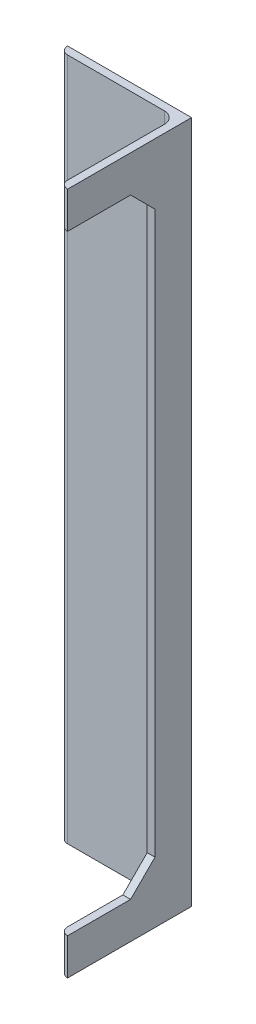
from build123d import *

# Parameters (mm, degrees)
ANGULAR_ALUMINIO_ANGULAR_38MM_1_DEPTH = 280
CROQUIS8_W                            = 35.8
CROQUIS8_H                            = 250
CORTAR_EXTRUIR1_DEPTH                 = 4
CHAFL_N1_SIZE                         = 10
CROQUIS10_R                           = 2
CORTAR_EXTRUIR3_DEPTH                 = 10
CROQUIS12_R                           = 2
CORTAR_EXTRUIR4_DEPTH                 = 10


with BuildPart() as part:
    # Sketch11 → Angular ALUMINIO ANGULAR 38MM(1) (new body)
    with BuildSketch(Plane(origin=(0, 0, 0), x_dir=(-1, 0, 0), z_dir=(0, 1, 0))):
        with BuildLine():
            Line((0, 0), (0, 50.8))
            Line((0, 50.8), (0.00508, 50.8))
            ThreePointArc((0.00508, 50.8), (2.246551928, 49.871551928), (3.175, 47.63008))
            Line((3.175, 47.63008), (3.175, 7.9375))
            ThreePointArc((3.175, 7.9375), (4.569903955, 4.569903955), (7.9375, 3.175))
            Line((7.9375, 3.175), (47.63008, 3.175))
            ThreePointArc((47.63008, 3.175), (49.871551928, 2.246551928), (50.8, 0.00508))
            Line((50.8, 0.00508), (50.8, 0))
            Line((50.8, 0), (0, 0))
        make_face()
    extrude(amount=ANGULAR_ALUMINIO_ANGULAR_38MM_1_DEPTH)

    # Croquis8 → Cortar-Extruir1 (cut)
    with BuildSketch(Plane(origin=(0, 0, 0), x_dir=(0, 0, -1), z_dir=(1, 0, 0))):
        with Locations((-32.9, 140)):
            Rectangle(CROQUIS8_W, CROQUIS8_H)
    extrude(amount=-CORTAR_EXTRUIR1_DEPTH, mode=Mode.SUBTRACT)

    # Chaflán1
    chafl_n1_edges = [part.edges().sort_by_distance(p)[0] for p in [
        (-1.5875, 265, 15),
        (-1.5875, 15, 15),
    ]]
    chamfer(chafl_n1_edges, length=CHAFL_N1_SIZE)

    # Croquis10 → Cortar-Extruir3 (cut)
    with BuildSketch(Plane(origin=(0, 0, 0), x_dir=(-1, 0, 0), z_dir=(0, 0, -1))):
        with Locations((5.675, 41)):
            Circle(CROQUIS10_R)
        with Locations((5.675, 11)):
            Circle(CROQUIS10_R)
        with Locations((-44.325, 41)):
            Circle(CROQUIS10_R)
        with Locations((-44.325, 11)):
            Circle(CROQUIS10_R)
    extrude(amount=-CORTAR_EXTRUIR3_DEPTH, mode=Mode.SUBTRACT)

    # Croquis12 → Cortar-Extruir4 (cut)
    with BuildSketch(Plane(origin=(0, 0, 0), x_dir=(-1, 0, 0), z_dir=(0, 0, -1))):
        with Locations((5.675, 269)):
            Circle(CROQUIS12_R)
        with Locations((5.675, 239)):
            Circle(CROQUIS12_R)
    extrude(amount=-CORTAR_EXTRUIR4_DEPTH, mode=Mode.SUBTRACT)


solid = part.part
